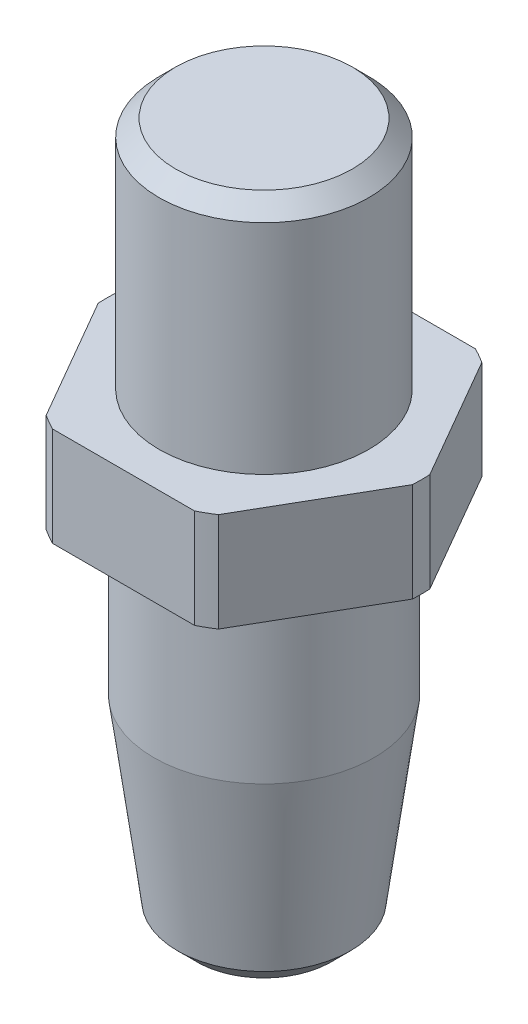
from build123d import *

# Parameters (mm, degrees)
CHAMFER1_SIZE         = 1
CHAMFER1_EDGE_2_SIZE2 = 1
CHAMFER1_EDGE_2_SIZE  = 1.162501902
SKETCH4_OUTSIDE_W     = 31.064
SKETCH4_OUTSIDE_H     = 31.064
CUT_EXTRUDE3_DEPTH    = 21.2


with BuildPart() as part:
    # Sketch1 → Revolve1 (revolve)
    with BuildSketch(Plane.XY):
        Polygon((-6.6675, 0), (-9.525, 0), (-9.525, 6), (-6.35, 6), (-6.35, 20.2), (0, 20.2), (0, -22), (-5.08, -22), (-6.6675, -10), align=None)
    revolve(axis=Axis((0, 72.046513776, 0), (0, -1, 0)))

    # Chamfer1
    chamfer1_edges = [part.edges().sort_by_distance(p)[0] for p in [
        (6.35, 20.2, 0),
    ]]
    chamfer(chamfer1_edges, length=CHAMFER1_SIZE)

    # Chamfer1 edge 2
    chamfer1_edge_2_edges = [part.edges().sort_by_distance(p)[0] for p in [
        (5.08, -22, 0),
    ]]
    chamfer(chamfer1_edge_2_edges, length=CHAMFER1_EDGE_2_SIZE, length2=CHAMFER1_EDGE_2_SIZE2)

    # Sketch4 outside → Cut-Extrude3 (cut, through all)
    with BuildSketch(Plane(origin=(0, 0, 0), x_dir=(1, 0, 0), z_dir=(0, 1, 0))):
        Rectangle(SKETCH4_OUTSIDE_W, SKETCH4_OUTSIDE_H)
        Polygon((9.814954576, 0), (4.907477288, 8.5), (-4.907477288, 8.5), (-9.814954576, 0), (-4.907477288, -8.5), (4.907477288, -8.5), align=None, mode=Mode.SUBTRACT)
    extrude(amount=CUT_EXTRUDE3_DEPTH, mode=Mode.SUBTRACT)


solid = part.part
